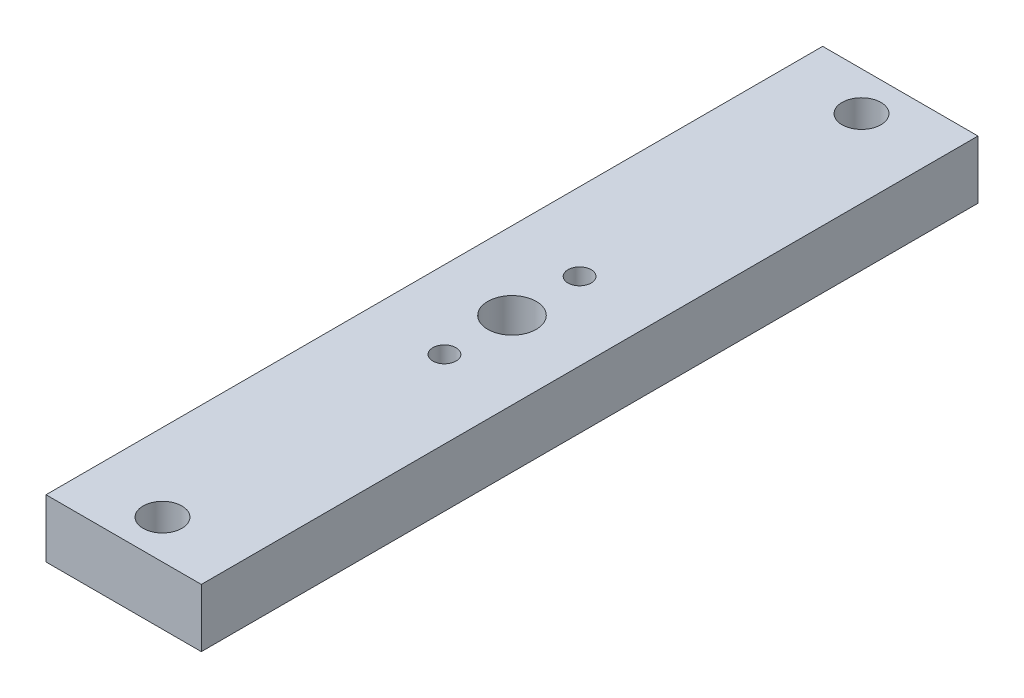
from build123d import *

# Parameters (mm, degrees)
SKETCH1_W                          = 25.4
SKETCH1_H                          = 9.525
EXTRUDE1_DEPTH                     = 127
F_1_4_0_25_DIAMETER_HOLE1_D        = 6.35
F_1_4_0_25_DIAMETER_HOLE1_DEPTH    = 12.7
F_1_4_0_25_DIAMETER_HOLE1_TIP      = 1.907732465
F_5_16_0_3125_DIAMETER_HOLE1_D     = 7.9375
F_5_16_0_3125_DIAMETER_HOLE1_DEPTH = 12.7
F_5_16_0_3125_DIAMETER_HOLE1_TIP   = 2.384665582
CIRPATTERN1_COUNT                  = 2


with BuildPart() as part:
    # Sketch1 → Extrude1 (new body)
    with BuildSketch(Plane.XY):
        Rectangle(SKETCH1_W, SKETCH1_H)
    extrude(amount=EXTRUDE1_DEPTH)

    # 1/4 (0.25) Diameter Hole1
    with Locations(Plane(origin=(0, 4.7625, 6.35), x_dir=(0, 0, 1), z_dir=(0, 1, 0))):
        with Locations((0, 0), (114.3, 0)):
            Hole(F_1_4_0_25_DIAMETER_HOLE1_D / 2, depth=F_1_4_0_25_DIAMETER_HOLE1_DEPTH)
            with Locations((0, 0, -(F_1_4_0_25_DIAMETER_HOLE1_DEPTH + F_1_4_0_25_DIAMETER_HOLE1_TIP / 2))):  # 118° drill point
                Cone(0, F_1_4_0_25_DIAMETER_HOLE1_D / 2, F_1_4_0_25_DIAMETER_HOLE1_TIP, mode=Mode.SUBTRACT)

    # 5/16 (0.3125) Diameter Hole1
    with Locations(Plane(origin=(0, 4.7625, 63.5), x_dir=(0, 0, 1), z_dir=(0, 1, 0))):
        with Locations((0, 0)):
            Hole(F_5_16_0_3125_DIAMETER_HOLE1_D / 2, depth=F_5_16_0_3125_DIAMETER_HOLE1_DEPTH)
            with Locations((0, 0, -(F_5_16_0_3125_DIAMETER_HOLE1_DEPTH + F_5_16_0_3125_DIAMETER_HOLE1_TIP / 2))):  # 118° drill point
                Cone(0, F_5_16_0_3125_DIAMETER_HOLE1_D / 2, F_5_16_0_3125_DIAMETER_HOLE1_TIP, mode=Mode.SUBTRACT)

    # Sketch6 → #25 (0.1495) Diameter Hole1 (revolve, cut)
    with BuildSketch(Plane(origin=(0, 4.7625, 74.549), x_dir=(0, 0, 1), z_dir=(1, 0, 0))):
        Polygon((0, 0), (0, 13.840824014), (1.89865, 12.7), (1.89865, 0), align=None)
    f_25_0_1495_diameter_hole1 = revolve(axis=Axis((0, 11.1125, 74.549), (0, -1, 0)), mode=Mode.SUBTRACT)

    # CirPattern1: #25 (0.1495) Diameter Hole1 ×2 about axis
    cirpattern1_axis = Axis((0, 0, 63.5), (0, 1, 0))
    for i in range(1, CIRPATTERN1_COUNT):
        add(f_25_0_1495_diameter_hole1.rotate(cirpattern1_axis, i * 360 / CIRPATTERN1_COUNT), mode=Mode.SUBTRACT)


solid = part.part
